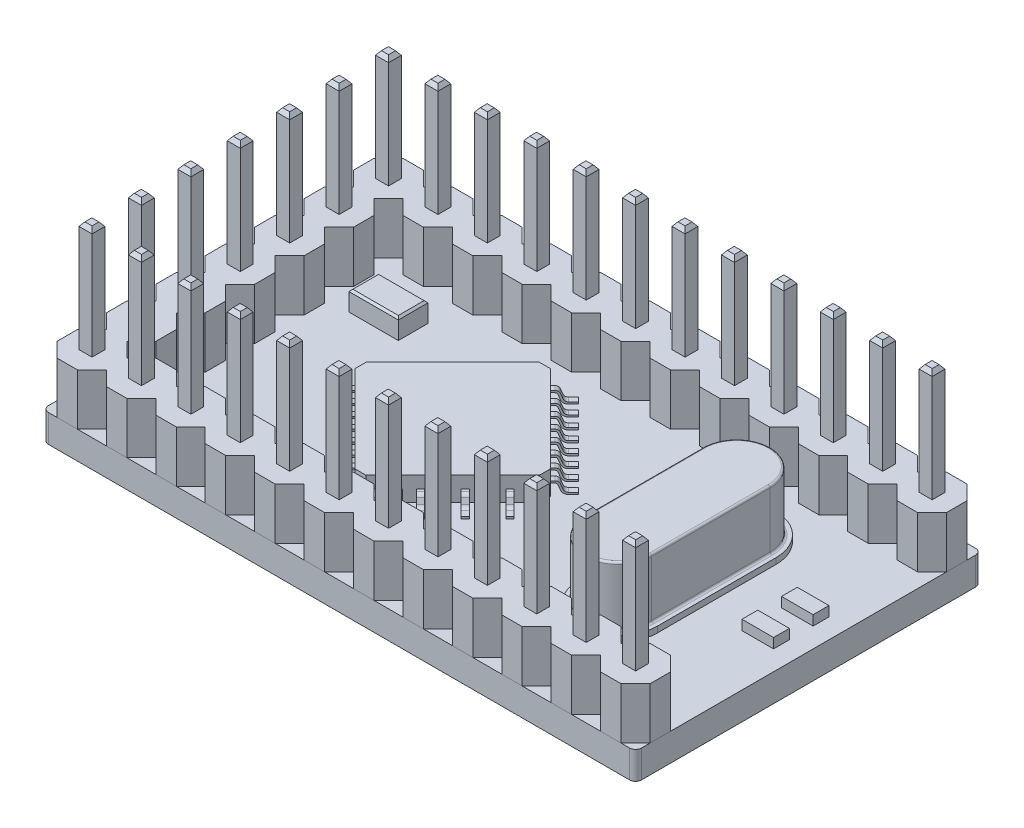
from build123d import *

# Parameters (mm, degrees)
SKETCH_1_W                                 = 30
SKETCH_1_H                                 = 17.5
EXTRUDE_1_DEPTH                            = 1.4
EXTRUDE_2_DEPTH                            = 2.6
SKETCH_4_W                                 = 0.66
SKETCH_4_H                                 = 0.65
EXTRUDE_3_DEPTH                            = 5.6
CHAMFER_1_SIZE                             = 0.2
CHAMFER_1_SIZE2                            = 0.15071081
CHAMFER_1_PART_2_SIZE                      = 0.2
CHAMFER_1_PART_2_SIZE2                     = 0.15071081
CHAMFER_1_PART_3_SIZE                      = 0.2
CHAMFER_1_PART_3_SIZE2                     = 0.15071081
CHAMFER_1_PART_4_SIZE                      = 0.2
CHAMFER_1_PART_4_SIZE2                     = 0.15071081
PATTERN_LINEAR_3_COUNT                     = 12
PATTERN_LINEAR_3_PITCH                     = 2.5
PATTERN_LINEAR_3_COUNT_DIR2                = 2
PATTERN_LINEAR_3_PITCH_DIR2                = 15
CHAMFER_1_OF_PATTERN_LINEAR_3_SIZE2        = 0.15071081
CHAMFER_1_OF_PATTERN_LINEAR_3_SIZE         = 0.2
CHAMFER_1_PART_2_OF_PATTERN_LINEAR_3_SIZE2 = 0.15071081
CHAMFER_1_PART_2_OF_PATTERN_LINEAR_3_SIZE  = 0.2
CHAMFER_1_PART_3_OF_PATTERN_LINEAR_3_SIZE2 = 0.15071081
CHAMFER_1_PART_3_OF_PATTERN_LINEAR_3_SIZE  = 0.2
CHAMFER_1_PART_4_OF_PATTERN_LINEAR_3_SIZE2 = 0.15071081
CHAMFER_1_PART_4_OF_PATTERN_LINEAR_3_SIZE  = 0.2
EXTRUDE_4_DEPTH                            = 1.2
CHAMFER_2_SIZE                             = 0.4
EXTRUDE_5_DEPTH                            = 0.3
PATTERN_LINEAR_4_COUNT                     = 8
PATTERN_LINEAR_4_PITCH                     = 0.8
EXTRUDE_6_DEPTH                            = 0.3
PATTERN_LINEAR_5_COUNT                     = 8
PATTERN_LINEAR_5_PITCH                     = 0.8
MIRROR_1_COPY_1_DEPTH                      = 0.3
MIRROR_1_COPY_2_DEPTH                      = 0.3
MIRROR_1_COPY_3_DEPTH                      = 0.3
MIRROR_1_COPY_4_DEPTH                      = 0.3
MIRROR_1_COPY_5_DEPTH                      = 0.3
MIRROR_1_COPY_6_DEPTH                      = 0.3
MIRROR_1_COPY_7_DEPTH                      = 0.3
MIRROR_2_COPY_1_DEPTH                      = 0.3
MIRROR_2_COPY_2_DEPTH                      = 0.3
MIRROR_2_COPY_3_DEPTH                      = 0.3
MIRROR_2_COPY_4_DEPTH                      = 0.3
MIRROR_2_COPY_5_DEPTH                      = 0.3
MIRROR_2_COPY_6_DEPTH                      = 0.3
MIRROR_2_COPY_7_DEPTH                      = 0.3
EXTRUDE_7_DEPTH                            = 0.3
EXTRUDE_8_DEPTH                            = 3
FILLET_1_R                                 = 0.1
FILLET_2_R                                 = 0.1
PATTERN_LINEAR_6_COUNT                     = 6
PATTERN_LINEAR_6_PITCH                     = 2.5
CHAMFER_1_OF_PATTERN_LINEAR_6_SIZE2        = 0.15071081
CHAMFER_1_OF_PATTERN_LINEAR_6_SIZE         = 0.2
CHAMFER_1_PART_2_OF_PATTERN_LINEAR_6_SIZE2 = 0.15071081
CHAMFER_1_PART_2_OF_PATTERN_LINEAR_6_SIZE  = 0.2
CHAMFER_1_PART_3_OF_PATTERN_LINEAR_6_SIZE2 = 0.15071081
CHAMFER_1_PART_3_OF_PATTERN_LINEAR_6_SIZE  = 0.2
CHAMFER_1_PART_4_OF_PATTERN_LINEAR_6_SIZE2 = 0.15071081
CHAMFER_1_PART_4_OF_PATTERN_LINEAR_6_SIZE  = 0.2
SKETCH_16_W                                = 2.5
SKETCH_16_H                                = 1.5
EXTRUDE_9_DEPTH                            = 1
CHAMFER_3_SIZE                             = 0.1
SKETCH_17_W                                = 1.6
SKETCH_17_H                                = 0.8
EXTRUDE_10_DEPTH                           = 0.5
FILLET_3_R                                 = 0.3


with BuildPart() as part:
    # 草图1 → 凸台-拉伸1 (new body)
    with BuildSketch(Plane(origin=(0, 0, 0), x_dir=(1, 0, 0), z_dir=(0, 1, 0))):
        with Locations((15, 8.75)):
            Rectangle(SKETCH_1_W, SKETCH_1_H)
    extrude(amount=EXTRUDE_1_DEPTH)


with BuildPart() as body_2:
    # 草图2 → 凸台-拉伸2 (new body)
    with BuildSketch(Plane(origin=(0, 1.4, 0), x_dir=(1, 0, 0), z_dir=(0, 1, 0))):
        Polygon((2.5, 15.732233047), (2.5, 16.767766953), (1.767766953, 17.5), (0.732233047, 17.5), (0, 16.767766953), (0, 15.732233047), (0.732233047, 15), (1.767766953, 15), align=None)
    extrude_2 = extrude(amount=EXTRUDE_2_DEPTH)


with BuildPart() as body_3:
    # 草图4 → 凸台-拉伸3 (new body)
    with BuildSketch(Plane(origin=(0, 4, 0), x_dir=(1, 0, 0), z_dir=(0, 1, 0))):
        with Locations((1.25, 16.25)):
            Rectangle(SKETCH_4_W, SKETCH_4_H)
    extrude_3 = extrude(amount=EXTRUDE_3_DEPTH)

    # 倒角1
    chamfer_1_edges = [body_3.edges().sort_by_distance(p)[0] for p in [
        (0.92, 9.6, -16.25),
    ]]
    chamfer_1_side = [body_3.faces().sort_by_distance(p)[0] for p in [
        (0.92, 6.8, -16.25),
    ]]
    chamfer(chamfer_1_edges, length=CHAMFER_1_SIZE, length2=CHAMFER_1_SIZE2, reference=chamfer_1_side[0])

    # 倒角1 part 2
    chamfer_1_part_2_edges = [body_3.edges().sort_by_distance(p)[0] for p in [
        (1.25, 9.6, -15.925),
    ]]
    chamfer_1_part_2_side = [body_3.faces().sort_by_distance(p)[0] for p in [
        (1.25, 6.8, -15.925),
    ]]
    chamfer(chamfer_1_part_2_edges, length=CHAMFER_1_PART_2_SIZE, length2=CHAMFER_1_PART_2_SIZE2, reference=chamfer_1_part_2_side[0])

    # 倒角1 part 3
    chamfer_1_part_3_edges = [body_3.edges().sort_by_distance(p)[0] for p in [
        (1.58, 9.6, -16.25),
    ]]
    chamfer_1_part_3_side = [body_3.faces().sort_by_distance(p)[0] for p in [
        (1.58, 6.8, -16.25),
    ]]
    chamfer(chamfer_1_part_3_edges, length=CHAMFER_1_PART_3_SIZE, length2=CHAMFER_1_PART_3_SIZE2, reference=chamfer_1_part_3_side[0])

    # 倒角1 part 4
    chamfer_1_part_4_edges = [body_3.edges().sort_by_distance(p)[0] for p in [
        (1.25, 9.6, -16.575),
    ]]
    chamfer_1_part_4_side = [body_3.faces().sort_by_distance(p)[0] for p in [
        (1.25, 6.8, -16.575),
    ]]
    chamfer(chamfer_1_part_4_edges, length=CHAMFER_1_PART_4_SIZE, length2=CHAMFER_1_PART_4_SIZE2, reference=chamfer_1_part_4_side[0])


with BuildPart() as part_1:
    add(part.part)

    add(body_2.part)  # 阵列(线性)3 merges body 2
    # 阵列(线性)3: 凸台-拉伸2, Extrude 3 12 × 2
    with Locations(*[(i * PATTERN_LINEAR_3_PITCH, 0, j * PATTERN_LINEAR_3_PITCH_DIR2) for i in range(PATTERN_LINEAR_3_COUNT) for j in range(PATTERN_LINEAR_3_COUNT_DIR2) if (i, j) != (0, 0)]):
        add(extrude_2)
        add(extrude_3)

    # 倒角1 of 阵列(线性)3
    chamfer_1_of_pattern_linear_3_edges = [part_1.edges().sort_by_distance(p)[0] for p in [
        (0.92, 9.6, -1.25),
        (3.42, 9.6, -16.25),
        (3.42, 9.6, -1.25),
        (5.92, 9.6, -16.25),
        (5.92, 9.6, -1.25),
        (8.42, 9.6, -16.25),
        (8.42, 9.6, -1.25),
        (10.92, 9.6, -16.25),
        (10.92, 9.6, -1.25),
        (13.42, 9.6, -16.25),
        (13.42, 9.6, -1.25),
        (15.92, 9.6, -16.25),
        (15.92, 9.6, -1.25),
        (18.42, 9.6, -16.25),
        (18.42, 9.6, -1.25),
        (20.92, 9.6, -16.25),
        (20.92, 9.6, -1.25),
        (23.42, 9.6, -16.25),
        (23.42, 9.6, -1.25),
        (25.92, 9.6, -16.25),
        (25.92, 9.6, -1.25),
        (28.42, 9.6, -16.25),
        (28.42, 9.6, -1.25),
    ]]
    chamfer(chamfer_1_of_pattern_linear_3_edges, length=CHAMFER_1_OF_PATTERN_LINEAR_3_SIZE, length2=CHAMFER_1_OF_PATTERN_LINEAR_3_SIZE2)

    # 倒角1 part 2 of 阵列(线性)3
    chamfer_1_part_2_of_pattern_linear_3_edges = [part_1.edges().sort_by_distance(p)[0] for p in [
        (1.25, 9.6, -0.925),
        (3.75, 9.6, -15.925),
        (3.75, 9.6, -0.925),
        (6.25, 9.6, -15.925),
        (6.25, 9.6, -0.925),
        (8.75, 9.6, -15.925),
        (8.75, 9.6, -0.925),
        (11.25, 9.6, -15.925),
        (11.25, 9.6, -0.925),
        (13.75, 9.6, -15.925),
        (13.75, 9.6, -0.925),
        (16.25, 9.6, -15.925),
        (16.25, 9.6, -0.925),
        (18.75, 9.6, -15.925),
        (18.75, 9.6, -0.925),
        (21.25, 9.6, -15.925),
        (21.25, 9.6, -0.925),
        (23.75, 9.6, -15.925),
        (23.75, 9.6, -0.925),
        (26.25, 9.6, -15.925),
        (26.25, 9.6, -0.925),
        (28.75, 9.6, -15.925),
        (28.75, 9.6, -0.925),
    ]]
    chamfer(chamfer_1_part_2_of_pattern_linear_3_edges, length=CHAMFER_1_PART_2_OF_PATTERN_LINEAR_3_SIZE, length2=CHAMFER_1_PART_2_OF_PATTERN_LINEAR_3_SIZE2)

    # 倒角1 part 3 of 阵列(线性)3
    chamfer_1_part_3_of_pattern_linear_3_edges = [part_1.edges().sort_by_distance(p)[0] for p in [
        (1.58, 9.6, -1.25),
        (4.08, 9.6, -16.25),
        (4.08, 9.6, -1.25),
        (6.58, 9.6, -16.25),
        (6.58, 9.6, -1.25),
        (9.08, 9.6, -16.25),
        (9.08, 9.6, -1.25),
        (11.58, 9.6, -16.25),
        (11.58, 9.6, -1.25),
        (14.08, 9.6, -16.25),
        (14.08, 9.6, -1.25),
        (16.58, 9.6, -16.25),
        (16.58, 9.6, -1.25),
        (19.08, 9.6, -16.25),
        (19.08, 9.6, -1.25),
        (21.58, 9.6, -16.25),
        (21.58, 9.6, -1.25),
        (24.08, 9.6, -16.25),
        (24.08, 9.6, -1.25),
        (26.58, 9.6, -16.25),
        (26.58, 9.6, -1.25),
        (29.08, 9.6, -16.25),
        (29.08, 9.6, -1.25),
    ]]
    chamfer(chamfer_1_part_3_of_pattern_linear_3_edges, length=CHAMFER_1_PART_3_OF_PATTERN_LINEAR_3_SIZE, length2=CHAMFER_1_PART_3_OF_PATTERN_LINEAR_3_SIZE2)

    # 倒角1 part 4 of 阵列(线性)3
    chamfer_1_part_4_of_pattern_linear_3_edges = [part_1.edges().sort_by_distance(p)[0] for p in [
        (1.25, 9.6, -1.575),
        (3.75, 9.6, -16.575),
        (3.75, 9.6, -1.575),
        (6.25, 9.6, -16.575),
        (6.25, 9.6, -1.575),
        (8.75, 9.6, -16.575),
        (8.75, 9.6, -1.575),
        (11.25, 9.6, -16.575),
        (11.25, 9.6, -1.575),
        (13.75, 9.6, -16.575),
        (13.75, 9.6, -1.575),
        (16.25, 9.6, -16.575),
        (16.25, 9.6, -1.575),
        (18.75, 9.6, -16.575),
        (18.75, 9.6, -1.575),
        (21.25, 9.6, -16.575),
        (21.25, 9.6, -1.575),
        (23.75, 9.6, -16.575),
        (23.75, 9.6, -1.575),
        (26.25, 9.6, -16.575),
        (26.25, 9.6, -1.575),
        (28.75, 9.6, -16.575),
        (28.75, 9.6, -1.575),
    ]]
    chamfer(chamfer_1_part_4_of_pattern_linear_3_edges, length=CHAMFER_1_PART_4_OF_PATTERN_LINEAR_3_SIZE, length2=CHAMFER_1_PART_4_OF_PATTERN_LINEAR_3_SIZE2)

    # 草图9 → 凸台-拉伸4 (add)
    with BuildSketch(Plane(origin=(0, 1.4, 0), x_dir=(1, 0, 0), z_dir=(0, 1, 0))):
        Polygon((7.050252532, 8.75), (12, 3.800252532), (16.949747468, 8.75), (12, 13.699747468), align=None)
    extrude(amount=EXTRUDE_4_DEPTH)

    # 倒角2
    chamfer_2_edges = [part_1.edges().sort_by_distance(p)[0] for p in [
        (12, 2, -13.699747468),
        (7.050252532, 2, -8.75),
        (12, 2, -3.800252532),
        (16.949747468, 2, -8.75),
    ]]
    chamfer(chamfer_2_edges, length=CHAMFER_2_SIZE)

    # 草图12 → 凸台-拉伸5 (add)
    with BuildSketch(Plane(origin=(12.496320344, 0, -12.496320344), x_dir=(-0.707106781, 0, -0.707106781), z_dir=(0.707106781, 0, -0.707106781))):
        with BuildLine():
            ThreePointArc((-6.155271653, 1.590990023), (-6.265506837, 1.452307658), (-6.434765526, 1.4))
            Line((-6.434765526, 1.4), (-6.798097039, 1.4))
            Line((-6.798097039, 1.4), (-6.798097039, 1.5))
            Line((-6.798097039, 1.5), (-6.434765526, 1.5))
            ThreePointArc((-6.434765526, 1.5), (-6.3219264, 1.534871772), (-6.248436277, 1.627326682))
            Line((-6.248436277, 1.627326682), (-6.152744623, 1.872673318))
            ThreePointArc((-6.152744623, 1.872673318), (-6.079254499, 1.965128228), (-5.966415374, 2))
            Line((-5.966415374, 2), (-5.798097039, 2))
            Line((-5.798097039, 2), (-5.798097039, 1.9))
            Line((-5.798097039, 1.9), (-5.966415374, 1.9))
            ThreePointArc((-5.966415374, 1.9), (-6.022834937, 1.882564114), (-6.059579998, 1.836336659))
            Line((-6.059579998, 1.836336659), (-6.155271653, 1.590990023))
        make_face()
    extrude_5 = extrude(amount=-EXTRUDE_5_DEPTH)

    # 阵列(线性)4: 凸台-拉伸5 ×8
    with Locations(*[Vector(-0.707106781, 0, 0.707106781) * (i * PATTERN_LINEAR_4_PITCH) for i in range(1, PATTERN_LINEAR_4_COUNT)]):
        add(extrude_5)

    # 草图13 → 凸台-拉伸6 (add)
    with BuildSketch(Plane(origin=(3.746320344, 0, 3.746320344), x_dir=(0.707106781, 0, -0.707106781), z_dir=(0.707106781, 0, 0.707106781))):
        with BuildLine():
            ThreePointArc((10.815602125, 1.588582797), (10.70524776, 1.451579831), (10.537059117, 1.4))
            Line((10.537059117, 1.4), (10.17246571, 1.4))
            Line((10.17246571, 1.4), (10.17246571, 1.5))
            Line((10.17246571, 1.5), (10.537059117, 1.5))
            ThreePointArc((10.537059117, 1.5), (10.649184879, 1.534386554), (10.722754456, 1.625721865))
            Line((10.722754456, 1.625721865), (10.822176964, 1.874278135))
            ThreePointArc((10.822176964, 1.874278135), (10.89574654, 1.965613446), (11.007872302, 2))
            Line((11.007872302, 2), (11.17246571, 2))
            Line((11.17246571, 2), (11.17246571, 1.9))
            Line((11.17246571, 1.9), (11.007872302, 1.9))
            ThreePointArc((11.007872302, 1.9), (10.951809421, 1.882806723), (10.915024633, 1.837139068))
            Line((10.915024633, 1.837139068), (10.815602125, 1.588582797))
        make_face()
    extrude_6 = extrude(amount=-EXTRUDE_6_DEPTH)

    # 阵列(线性)5: 凸台-拉伸6 ×8
    with Locations(*[Vector(-0.707106781, 0, -0.707106781) * (i * PATTERN_LINEAR_5_PITCH) for i in range(1, PATTERN_LINEAR_5_COUNT)]):
        add(extrude_6)

    # 镜向1: 凸台-拉伸6 across plane
    add(extrude_6.mirror(Plane(origin=(10.375, 0, -10.375), x_dir=(0.707106781, 0, 0.707106781), z_dir=(0.707106781, 0, -0.707106781))))

    # 镜向1 copy 1 sketch → 镜向1 copy 1 (add)
    with BuildSketch(Plane(origin=(23.930634919, 0, -17.569365081), x_dir=(-0.707106781, 0, 0.707106781), z_dir=(0.707106781, 0, 0.707106781))):
        with BuildLine():
            ThreePointArc((10.815602125, -1.588582797), (10.70524776, -1.451579831), (10.537059117, -1.4))
            Line((10.537059117, -1.4), (10.17246571, -1.4))
            Line((10.17246571, -1.4), (10.17246571, -1.5))
            Line((10.17246571, -1.5), (10.537059117, -1.5))
            ThreePointArc((10.537059117, -1.5), (10.649184879, -1.534386554), (10.722754456, -1.625721865))
            Line((10.722754456, -1.625721865), (10.822176964, -1.874278135))
            ThreePointArc((10.822176964, -1.874278135), (10.89574654, -1.965613446), (11.007872302, -2))
            Line((11.007872302, -2), (11.17246571, -2))
            Line((11.17246571, -2), (11.17246571, -1.9))
            Line((11.17246571, -1.9), (11.007872302, -1.9))
            ThreePointArc((11.007872302, -1.9), (10.951809421, -1.882806723), (10.915024633, -1.837139068))
            Line((10.915024633, -1.837139068), (10.815602125, -1.588582797))
        make_face()
    extrude(amount=-MIRROR_1_COPY_1_DEPTH)

    # 镜向1 copy 2 sketch → 镜向1 copy 2 (add)
    with BuildSketch(Plane(origin=(23.364949494, 0, -18.135050506), x_dir=(-0.707106781, 0, 0.707106781), z_dir=(0.707106781, 0, 0.707106781))):
        with BuildLine():
            ThreePointArc((10.815602125, -1.588582797), (10.70524776, -1.451579831), (10.537059117, -1.4))
            Line((10.537059117, -1.4), (10.17246571, -1.4))
            Line((10.17246571, -1.4), (10.17246571, -1.5))
            Line((10.17246571, -1.5), (10.537059117, -1.5))
            ThreePointArc((10.537059117, -1.5), (10.649184879, -1.534386554), (10.722754456, -1.625721865))
            Line((10.722754456, -1.625721865), (10.822176964, -1.874278135))
            ThreePointArc((10.822176964, -1.874278135), (10.89574654, -1.965613446), (11.007872302, -2))
            Line((11.007872302, -2), (11.17246571, -2))
            Line((11.17246571, -2), (11.17246571, -1.9))
            Line((11.17246571, -1.9), (11.007872302, -1.9))
            ThreePointArc((11.007872302, -1.9), (10.951809421, -1.882806723), (10.915024633, -1.837139068))
            Line((10.915024633, -1.837139068), (10.815602125, -1.588582797))
        make_face()
    extrude(amount=-MIRROR_1_COPY_2_DEPTH)

    # 镜向1 copy 3 sketch → 镜向1 copy 3 (add)
    with BuildSketch(Plane(origin=(22.799264069, 0, -18.700735931), x_dir=(-0.707106781, 0, 0.707106781), z_dir=(0.707106781, 0, 0.707106781))):
        with BuildLine():
            ThreePointArc((10.815602125, -1.588582797), (10.70524776, -1.451579831), (10.537059117, -1.4))
            Line((10.537059117, -1.4), (10.17246571, -1.4))
            Line((10.17246571, -1.4), (10.17246571, -1.5))
            Line((10.17246571, -1.5), (10.537059117, -1.5))
            ThreePointArc((10.537059117, -1.5), (10.649184879, -1.534386554), (10.722754456, -1.625721865))
            Line((10.722754456, -1.625721865), (10.822176964, -1.874278135))
            ThreePointArc((10.822176964, -1.874278135), (10.89574654, -1.965613446), (11.007872302, -2))
            Line((11.007872302, -2), (11.17246571, -2))
            Line((11.17246571, -2), (11.17246571, -1.9))
            Line((11.17246571, -1.9), (11.007872302, -1.9))
            ThreePointArc((11.007872302, -1.9), (10.951809421, -1.882806723), (10.915024633, -1.837139068))
            Line((10.915024633, -1.837139068), (10.815602125, -1.588582797))
        make_face()
    extrude(amount=-MIRROR_1_COPY_3_DEPTH)

    # 镜向1 copy 4 sketch → 镜向1 copy 4 (add)
    with BuildSketch(Plane(origin=(22.233578644, 0, -19.266421356), x_dir=(-0.707106781, 0, 0.707106781), z_dir=(0.707106781, 0, 0.707106781))):
        with BuildLine():
            ThreePointArc((10.815602125, -1.588582797), (10.70524776, -1.451579831), (10.537059117, -1.4))
            Line((10.537059117, -1.4), (10.17246571, -1.4))
            Line((10.17246571, -1.4), (10.17246571, -1.5))
            Line((10.17246571, -1.5), (10.537059117, -1.5))
            ThreePointArc((10.537059117, -1.5), (10.649184879, -1.534386554), (10.722754456, -1.625721865))
            Line((10.722754456, -1.625721865), (10.822176964, -1.874278135))
            ThreePointArc((10.822176964, -1.874278135), (10.89574654, -1.965613446), (11.007872302, -2))
            Line((11.007872302, -2), (11.17246571, -2))
            Line((11.17246571, -2), (11.17246571, -1.9))
            Line((11.17246571, -1.9), (11.007872302, -1.9))
            ThreePointArc((11.007872302, -1.9), (10.951809421, -1.882806723), (10.915024633, -1.837139068))
            Line((10.915024633, -1.837139068), (10.815602125, -1.588582797))
        make_face()
    extrude(amount=-MIRROR_1_COPY_4_DEPTH)

    # 镜向1 copy 5 sketch → 镜向1 copy 5 (add)
    with BuildSketch(Plane(origin=(21.667893219, 0, -19.832106781), x_dir=(-0.707106781, 0, 0.707106781), z_dir=(0.707106781, 0, 0.707106781))):
        with BuildLine():
            ThreePointArc((10.815602125, -1.588582797), (10.70524776, -1.451579831), (10.537059117, -1.4))
            Line((10.537059117, -1.4), (10.17246571, -1.4))
            Line((10.17246571, -1.4), (10.17246571, -1.5))
            Line((10.17246571, -1.5), (10.537059117, -1.5))
            ThreePointArc((10.537059117, -1.5), (10.649184879, -1.534386554), (10.722754456, -1.625721865))
            Line((10.722754456, -1.625721865), (10.822176964, -1.874278135))
            ThreePointArc((10.822176964, -1.874278135), (10.89574654, -1.965613446), (11.007872302, -2))
            Line((11.007872302, -2), (11.17246571, -2))
            Line((11.17246571, -2), (11.17246571, -1.9))
            Line((11.17246571, -1.9), (11.007872302, -1.9))
            ThreePointArc((11.007872302, -1.9), (10.951809421, -1.882806723), (10.915024633, -1.837139068))
            Line((10.915024633, -1.837139068), (10.815602125, -1.588582797))
        make_face()
    extrude(amount=-MIRROR_1_COPY_5_DEPTH)

    # 镜向1 copy 6 sketch → 镜向1 copy 6 (add)
    with BuildSketch(Plane(origin=(21.102207794, 0, -20.397792206), x_dir=(-0.707106781, 0, 0.707106781), z_dir=(0.707106781, 0, 0.707106781))):
        with BuildLine():
            ThreePointArc((10.815602125, -1.588582797), (10.70524776, -1.451579831), (10.537059117, -1.4))
            Line((10.537059117, -1.4), (10.17246571, -1.4))
            Line((10.17246571, -1.4), (10.17246571, -1.5))
            Line((10.17246571, -1.5), (10.537059117, -1.5))
            ThreePointArc((10.537059117, -1.5), (10.649184879, -1.534386554), (10.722754456, -1.625721865))
            Line((10.722754456, -1.625721865), (10.822176964, -1.874278135))
            ThreePointArc((10.822176964, -1.874278135), (10.89574654, -1.965613446), (11.007872302, -2))
            Line((11.007872302, -2), (11.17246571, -2))
            Line((11.17246571, -2), (11.17246571, -1.9))
            Line((11.17246571, -1.9), (11.007872302, -1.9))
            ThreePointArc((11.007872302, -1.9), (10.951809421, -1.882806723), (10.915024633, -1.837139068))
            Line((10.915024633, -1.837139068), (10.815602125, -1.588582797))
        make_face()
    extrude(amount=-MIRROR_1_COPY_6_DEPTH)

    # 镜向1 copy 7 sketch → 镜向1 copy 7 (add)
    with BuildSketch(Plane(origin=(20.536522369, 0, -20.963477631), x_dir=(-0.707106781, 0, 0.707106781), z_dir=(0.707106781, 0, 0.707106781))):
        with BuildLine():
            ThreePointArc((10.815602125, -1.588582797), (10.70524776, -1.451579831), (10.537059117, -1.4))
            Line((10.537059117, -1.4), (10.17246571, -1.4))
            Line((10.17246571, -1.4), (10.17246571, -1.5))
            Line((10.17246571, -1.5), (10.537059117, -1.5))
            ThreePointArc((10.537059117, -1.5), (10.649184879, -1.534386554), (10.722754456, -1.625721865))
            Line((10.722754456, -1.625721865), (10.822176964, -1.874278135))
            ThreePointArc((10.822176964, -1.874278135), (10.89574654, -1.965613446), (11.007872302, -2))
            Line((11.007872302, -2), (11.17246571, -2))
            Line((11.17246571, -2), (11.17246571, -1.9))
            Line((11.17246571, -1.9), (11.007872302, -1.9))
            ThreePointArc((11.007872302, -1.9), (10.951809421, -1.882806723), (10.915024633, -1.837139068))
            Line((10.915024633, -1.837139068), (10.815602125, -1.588582797))
        make_face()
    extrude(amount=-MIRROR_1_COPY_7_DEPTH)

    # 镜向2: 凸台-拉伸5 across plane
    add(extrude_5.mirror(Plane(origin=(1.625, 0, 1.625), x_dir=(-0.707106781, 0, 0.707106781), z_dir=(-0.707106781, 0, -0.707106781))))

    # 镜向2 copy 1 sketch → 镜向2 copy 1 (add)
    with BuildSketch(Plane(origin=(15.180634919, 0, -8.680634919), x_dir=(0.707106781, 0, 0.707106781), z_dir=(0.707106781, 0, -0.707106781))):
        with BuildLine():
            ThreePointArc((-6.155271653, -1.590990023), (-6.265506837, -1.452307658), (-6.434765526, -1.4))
            Line((-6.434765526, -1.4), (-6.798097039, -1.4))
            Line((-6.798097039, -1.4), (-6.798097039, -1.5))
            Line((-6.798097039, -1.5), (-6.434765526, -1.5))
            ThreePointArc((-6.434765526, -1.5), (-6.3219264, -1.534871772), (-6.248436277, -1.627326682))
            Line((-6.248436277, -1.627326682), (-6.152744623, -1.872673318))
            ThreePointArc((-6.152744623, -1.872673318), (-6.079254499, -1.965128228), (-5.966415374, -2))
            Line((-5.966415374, -2), (-5.798097039, -2))
            Line((-5.798097039, -2), (-5.798097039, -1.9))
            Line((-5.798097039, -1.9), (-5.966415374, -1.9))
            ThreePointArc((-5.966415374, -1.9), (-6.022834937, -1.882564114), (-6.059579998, -1.836336659))
            Line((-6.059579998, -1.836336659), (-6.155271653, -1.590990023))
        make_face()
    extrude(amount=-MIRROR_2_COPY_1_DEPTH)

    # 镜向2 copy 2 sketch → 镜向2 copy 2 (add)
    with BuildSketch(Plane(origin=(14.614949494, 0, -8.114949494), x_dir=(0.707106781, 0, 0.707106781), z_dir=(0.707106781, 0, -0.707106781))):
        with BuildLine():
            ThreePointArc((-6.155271653, -1.590990023), (-6.265506837, -1.452307658), (-6.434765526, -1.4))
            Line((-6.434765526, -1.4), (-6.798097039, -1.4))
            Line((-6.798097039, -1.4), (-6.798097039, -1.5))
            Line((-6.798097039, -1.5), (-6.434765526, -1.5))
            ThreePointArc((-6.434765526, -1.5), (-6.3219264, -1.534871772), (-6.248436277, -1.627326682))
            Line((-6.248436277, -1.627326682), (-6.152744623, -1.872673318))
            ThreePointArc((-6.152744623, -1.872673318), (-6.079254499, -1.965128228), (-5.966415374, -2))
            Line((-5.966415374, -2), (-5.798097039, -2))
            Line((-5.798097039, -2), (-5.798097039, -1.9))
            Line((-5.798097039, -1.9), (-5.966415374, -1.9))
            ThreePointArc((-5.966415374, -1.9), (-6.022834937, -1.882564114), (-6.059579998, -1.836336659))
            Line((-6.059579998, -1.836336659), (-6.155271653, -1.590990023))
        make_face()
    extrude(amount=-MIRROR_2_COPY_2_DEPTH)

    # 镜向2 copy 3 sketch → 镜向2 copy 3 (add)
    with BuildSketch(Plane(origin=(14.049264069, 0, -7.549264069), x_dir=(0.707106781, 0, 0.707106781), z_dir=(0.707106781, 0, -0.707106781))):
        with BuildLine():
            ThreePointArc((-6.155271653, -1.590990023), (-6.265506837, -1.452307658), (-6.434765526, -1.4))
            Line((-6.434765526, -1.4), (-6.798097039, -1.4))
            Line((-6.798097039, -1.4), (-6.798097039, -1.5))
            Line((-6.798097039, -1.5), (-6.434765526, -1.5))
            ThreePointArc((-6.434765526, -1.5), (-6.3219264, -1.534871772), (-6.248436277, -1.627326682))
            Line((-6.248436277, -1.627326682), (-6.152744623, -1.872673318))
            ThreePointArc((-6.152744623, -1.872673318), (-6.079254499, -1.965128228), (-5.966415374, -2))
            Line((-5.966415374, -2), (-5.798097039, -2))
            Line((-5.798097039, -2), (-5.798097039, -1.9))
            Line((-5.798097039, -1.9), (-5.966415374, -1.9))
            ThreePointArc((-5.966415374, -1.9), (-6.022834937, -1.882564114), (-6.059579998, -1.836336659))
            Line((-6.059579998, -1.836336659), (-6.155271653, -1.590990023))
        make_face()
    extrude(amount=-MIRROR_2_COPY_3_DEPTH)

    # 镜向2 copy 4 sketch → 镜向2 copy 4 (add)
    with BuildSketch(Plane(origin=(13.483578644, 0, -6.983578644), x_dir=(0.707106781, 0, 0.707106781), z_dir=(0.707106781, 0, -0.707106781))):
        with BuildLine():
            ThreePointArc((-6.155271653, -1.590990023), (-6.265506837, -1.452307658), (-6.434765526, -1.4))
            Line((-6.434765526, -1.4), (-6.798097039, -1.4))
            Line((-6.798097039, -1.4), (-6.798097039, -1.5))
            Line((-6.798097039, -1.5), (-6.434765526, -1.5))
            ThreePointArc((-6.434765526, -1.5), (-6.3219264, -1.534871772), (-6.248436277, -1.627326682))
            Line((-6.248436277, -1.627326682), (-6.152744623, -1.872673318))
            ThreePointArc((-6.152744623, -1.872673318), (-6.079254499, -1.965128228), (-5.966415374, -2))
            Line((-5.966415374, -2), (-5.798097039, -2))
            Line((-5.798097039, -2), (-5.798097039, -1.9))
            Line((-5.798097039, -1.9), (-5.966415374, -1.9))
            ThreePointArc((-5.966415374, -1.9), (-6.022834937, -1.882564114), (-6.059579998, -1.836336659))
            Line((-6.059579998, -1.836336659), (-6.155271653, -1.590990023))
        make_face()
    extrude(amount=-MIRROR_2_COPY_4_DEPTH)

    # 镜向2 copy 5 sketch → 镜向2 copy 5 (add)
    with BuildSketch(Plane(origin=(12.917893219, 0, -6.417893219), x_dir=(0.707106781, 0, 0.707106781), z_dir=(0.707106781, 0, -0.707106781))):
        with BuildLine():
            ThreePointArc((-6.155271653, -1.590990023), (-6.265506837, -1.452307658), (-6.434765526, -1.4))
            Line((-6.434765526, -1.4), (-6.798097039, -1.4))
            Line((-6.798097039, -1.4), (-6.798097039, -1.5))
            Line((-6.798097039, -1.5), (-6.434765526, -1.5))
            ThreePointArc((-6.434765526, -1.5), (-6.3219264, -1.534871772), (-6.248436277, -1.627326682))
            Line((-6.248436277, -1.627326682), (-6.152744623, -1.872673318))
            ThreePointArc((-6.152744623, -1.872673318), (-6.079254499, -1.965128228), (-5.966415374, -2))
            Line((-5.966415374, -2), (-5.798097039, -2))
            Line((-5.798097039, -2), (-5.798097039, -1.9))
            Line((-5.798097039, -1.9), (-5.966415374, -1.9))
            ThreePointArc((-5.966415374, -1.9), (-6.022834937, -1.882564114), (-6.059579998, -1.836336659))
            Line((-6.059579998, -1.836336659), (-6.155271653, -1.590990023))
        make_face()
    extrude(amount=-MIRROR_2_COPY_5_DEPTH)

    # 镜向2 copy 6 sketch → 镜向2 copy 6 (add)
    with BuildSketch(Plane(origin=(12.352207794, 0, -5.852207794), x_dir=(0.707106781, 0, 0.707106781), z_dir=(0.707106781, 0, -0.707106781))):
        with BuildLine():
            ThreePointArc((-6.155271653, -1.590990023), (-6.265506837, -1.452307658), (-6.434765526, -1.4))
            Line((-6.434765526, -1.4), (-6.798097039, -1.4))
            Line((-6.798097039, -1.4), (-6.798097039, -1.5))
            Line((-6.798097039, -1.5), (-6.434765526, -1.5))
            ThreePointArc((-6.434765526, -1.5), (-6.3219264, -1.534871772), (-6.248436277, -1.627326682))
            Line((-6.248436277, -1.627326682), (-6.152744623, -1.872673318))
            ThreePointArc((-6.152744623, -1.872673318), (-6.079254499, -1.965128228), (-5.966415374, -2))
            Line((-5.966415374, -2), (-5.798097039, -2))
            Line((-5.798097039, -2), (-5.798097039, -1.9))
            Line((-5.798097039, -1.9), (-5.966415374, -1.9))
            ThreePointArc((-5.966415374, -1.9), (-6.022834937, -1.882564114), (-6.059579998, -1.836336659))
            Line((-6.059579998, -1.836336659), (-6.155271653, -1.590990023))
        make_face()
    extrude(amount=-MIRROR_2_COPY_6_DEPTH)

    # 镜向2 copy 7 sketch → 镜向2 copy 7 (add)
    with BuildSketch(Plane(origin=(11.786522369, 0, -5.286522369), x_dir=(0.707106781, 0, 0.707106781), z_dir=(0.707106781, 0, -0.707106781))):
        with BuildLine():
            ThreePointArc((-6.155271653, -1.590990023), (-6.265506837, -1.452307658), (-6.434765526, -1.4))
            Line((-6.434765526, -1.4), (-6.798097039, -1.4))
            Line((-6.798097039, -1.4), (-6.798097039, -1.5))
            Line((-6.798097039, -1.5), (-6.434765526, -1.5))
            ThreePointArc((-6.434765526, -1.5), (-6.3219264, -1.534871772), (-6.248436277, -1.627326682))
            Line((-6.248436277, -1.627326682), (-6.152744623, -1.872673318))
            ThreePointArc((-6.152744623, -1.872673318), (-6.079254499, -1.965128228), (-5.966415374, -2))
            Line((-5.966415374, -2), (-5.798097039, -2))
            Line((-5.798097039, -2), (-5.798097039, -1.9))
            Line((-5.798097039, -1.9), (-5.966415374, -1.9))
            ThreePointArc((-5.966415374, -1.9), (-6.022834937, -1.882564114), (-6.059579998, -1.836336659))
            Line((-6.059579998, -1.836336659), (-6.155271653, -1.590990023))
        make_face()
    extrude(amount=-MIRROR_2_COPY_7_DEPTH)

    # 草图14 → 凸台-拉伸7 (add)
    with BuildSketch(Plane(origin=(0, 1.4, 0), x_dir=(1, 0, 0), z_dir=(0, 1, 0))):
        with BuildLine():
            Line((25.36249097, 11.75), (25.36249097, 5.75))
            ThreePointArc((25.36249097, 5.75), (23.36249097, 3.75), (21.36249097, 5.75))
            Line((21.36249097, 5.75), (21.36249097, 11.75))
            ThreePointArc((21.36249097, 11.75), (23.36249097, 13.75), (25.36249097, 11.75))
        make_face()
    extrude(amount=EXTRUDE_7_DEPTH)

    # 草图15 → 凸台-拉伸8 (add)
    with BuildSketch(Plane(origin=(0, 1.7, 0), x_dir=(1, 0, 0), z_dir=(0, 1, 0))):
        with BuildLine():
            Line((21.66249097, 11.75), (21.66249097, 5.75))
            ThreePointArc((21.66249097, 5.75), (23.36249097, 4.05), (25.06249097, 5.75))
            Line((25.06249097, 5.75), (25.06249097, 11.75))
            ThreePointArc((25.06249097, 11.75), (23.36249097, 13.45), (21.66249097, 11.75))
        make_face()
    extrude(amount=EXTRUDE_8_DEPTH)

    # 圆角1
    fillet_1_edges = [part_1.edges().sort_by_distance(p)[0] for p in [
        (23.36249097, 1.7, -13.45),
        (21.66249097, 1.7, -8.75),
        (23.36249097, 1.7, -4.05),
        (25.06249097, 1.7, -8.75),
    ]]
    fillet(fillet_1_edges, radius=FILLET_1_R)

    # 圆角2
    fillet_2_edges = [part_1.edges().sort_by_distance(p)[0] for p in [
        (23.36249097, 4.7, -13.45),
        (21.66249097, 4.7, -8.75),
        (23.36249097, 4.7, -4.05),
        (25.06249097, 4.7, -8.75),
    ]]
    fillet(fillet_2_edges, radius=FILLET_2_R)

    # 阵列(线性)6: 凸台-拉伸2, 凸台-拉伸3 ×6
    with Locations(*[(0, 0, i * PATTERN_LINEAR_6_PITCH) for i in range(1, PATTERN_LINEAR_6_COUNT)]):
        add(extrude_2)
        add(extrude_3)

    # 倒角1 of 阵列(线性)6
    chamfer_1_of_pattern_linear_6_edges = [part_1.edges().sort_by_distance(p)[0] for p in [
        (0.92, 9.6, -13.75),
        (0.92, 9.6, -11.25),
        (0.92, 9.6, -8.75),
        (0.92, 9.6, -6.25),
        (0.92, 9.6, -3.75),
    ]]
    chamfer(chamfer_1_of_pattern_linear_6_edges, length=CHAMFER_1_OF_PATTERN_LINEAR_6_SIZE, length2=CHAMFER_1_OF_PATTERN_LINEAR_6_SIZE2)

    # 倒角1 part 2 of 阵列(线性)6
    chamfer_1_part_2_of_pattern_linear_6_edges = [part_1.edges().sort_by_distance(p)[0] for p in [
        (1.25, 9.6, -13.425),
        (1.25, 9.6, -10.925),
        (1.25, 9.6, -8.425),
        (1.25, 9.6, -5.925),
        (1.25, 9.6, -3.425),
    ]]
    chamfer(chamfer_1_part_2_of_pattern_linear_6_edges, length=CHAMFER_1_PART_2_OF_PATTERN_LINEAR_6_SIZE, length2=CHAMFER_1_PART_2_OF_PATTERN_LINEAR_6_SIZE2)

    # 倒角1 part 3 of 阵列(线性)6
    chamfer_1_part_3_of_pattern_linear_6_edges = [part_1.edges().sort_by_distance(p)[0] for p in [
        (1.58, 9.6, -13.75),
        (1.58, 9.6, -11.25),
        (1.58, 9.6, -8.75),
        (1.58, 9.6, -6.25),
        (1.58, 9.6, -3.75),
    ]]
    chamfer(chamfer_1_part_3_of_pattern_linear_6_edges, length=CHAMFER_1_PART_3_OF_PATTERN_LINEAR_6_SIZE, length2=CHAMFER_1_PART_3_OF_PATTERN_LINEAR_6_SIZE2)

    # 倒角1 part 4 of 阵列(线性)6
    chamfer_1_part_4_of_pattern_linear_6_edges = [part_1.edges().sort_by_distance(p)[0] for p in [
        (1.25, 9.6, -14.075),
        (1.25, 9.6, -11.575),
        (1.25, 9.6, -9.075),
        (1.25, 9.6, -6.575),
        (1.25, 9.6, -4.075),
    ]]
    chamfer(chamfer_1_part_4_of_pattern_linear_6_edges, length=CHAMFER_1_PART_4_OF_PATTERN_LINEAR_6_SIZE, length2=CHAMFER_1_PART_4_OF_PATTERN_LINEAR_6_SIZE2)

    # 草图16 → 凸台-拉伸9 (add)
    with BuildSketch(Plane(origin=(0, 1.4, 0), x_dir=(1, 0, 0), z_dir=(0, 1, 0))):
        with Locations((4.75, 12.75)):
            Rectangle(SKETCH_16_W, SKETCH_16_H)
    extrude(amount=EXTRUDE_9_DEPTH)

    # 倒角3
    chamfer_3_edges = [part_1.edges().sort_by_distance(p)[0] for p in [
        (3.5, 2.4, -12.75),
        (4.75, 2.4, -12),
        (6, 2.4, -12.75),
        (4.75, 2.4, -13.5),
    ]]
    chamfer(chamfer_3_edges, length=CHAMFER_3_SIZE)

    # 草图17 → 凸台-拉伸10 (add)
    with BuildSketch(Plane(origin=(0, 1.4, 0), x_dir=(1, 0, 0), z_dir=(0, 1, 0))):
        with Locations((28.2, 10.382091499)):
            Rectangle(SKETCH_17_W, SKETCH_17_H)
        with Locations((28.2, 8.382091499)):
            Rectangle(SKETCH_17_W, SKETCH_17_H)
    extrude(amount=EXTRUDE_10_DEPTH)

    # 圆角3
    fillet_3_edges = [part_1.edges().sort_by_distance(p)[0] for p in [
        (0, 0.7, 0),
        (0, 0.7, -17.5),
        (30, 0.7, -17.5),
        (30, 0.7, 0),
    ]]
    fillet(fillet_3_edges, radius=FILLET_3_R)


solid = Compound([body_3.part, part_1.part])
